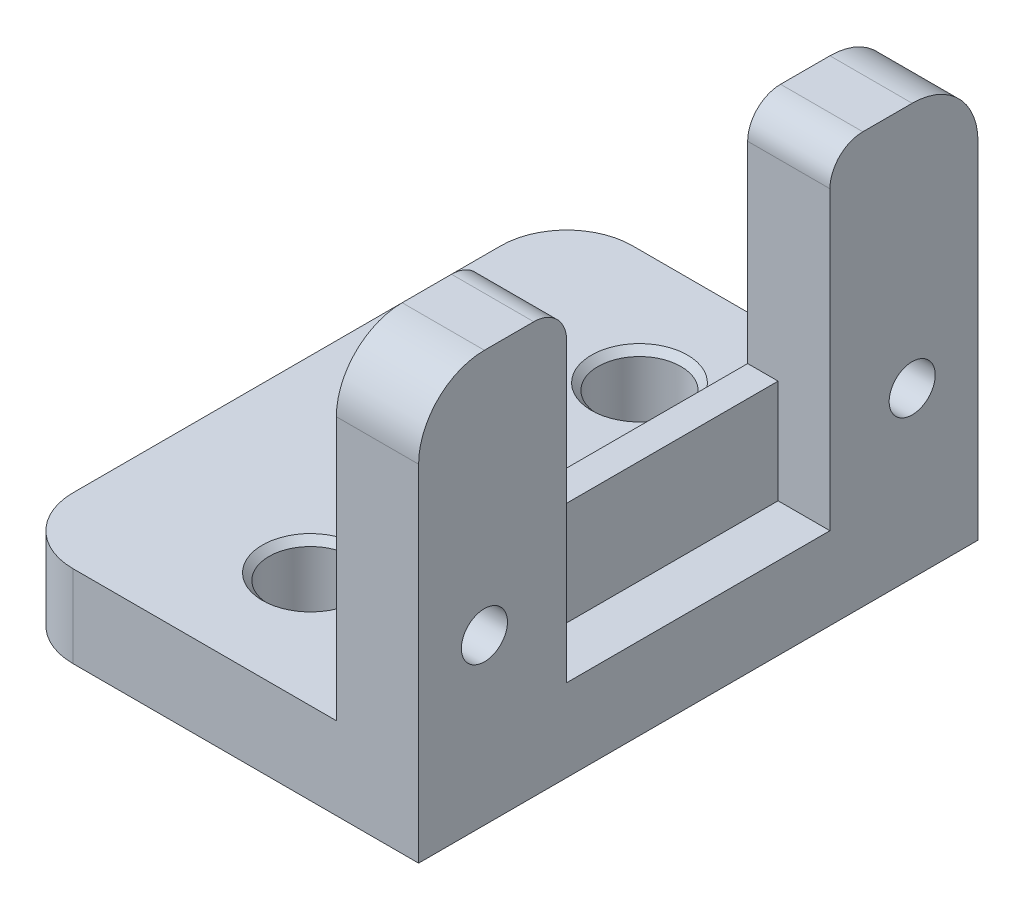
from build123d import *

# Parameters (mm, degrees)
BOSS_EXTRUDE1_DEPTH = 10.795
SKETCH2_R           = 0.889
SKETCH2_W           = 10.16
SKETCH2_H           = 12.7
CUT_EXTRUDE1_DEPTH  = 16.875
SKETCH3_R           = 1.6
CUT_EXTRUDE2_DEPTH  = 4.175
SKETCH5_W           = 1.175
SKETCH5_H           = 10.16
BOSS_EXTRUDE2_DEPTH = 4
CHAMFER1_SIZE       = 0.254
FILLET1_R           = 2.54
FILLET2_R           = 1.27


with BuildPart() as part:
    # Sketch1 → Boss-Extrude1 (new body, symmetric)
    with BuildSketch(Plane.XY):
        Polygon((-15.875, 0), (0, 0), (0, 15.875), (-3.175, 15.875), (-3.175, 3.175), (-15.875, 3.175), align=None)
    extrude(amount=BOSS_EXTRUDE1_DEPTH, both=True)

    # Sketch2 → Cut-Extrude1 (cut, through all)
    with BuildSketch(Plane(origin=(0, 0, 0), x_dir=(0, 0, -1), z_dir=(1, 0, 0))):
        with Locations((-8.255, 6.35)):
            Circle(SKETCH2_R)
        with Locations((8.255, 6.35)):
            Circle(SKETCH2_R)
        with Locations((0, 9.525)):
            Rectangle(SKETCH2_W, SKETCH2_H)
    extrude(amount=-CUT_EXTRUDE1_DEPTH, mode=Mode.SUBTRACT)

    # Sketch3 → Cut-Extrude2 (cut, through all)
    with BuildSketch(Plane(origin=(0, 3.175, 0), x_dir=(1, 0, 0), z_dir=(0, 1, 0))):
        with Locations((-8.62, 6.35)):
            Circle(SKETCH3_R)
        with Locations((-8.62, -6.35)):
            Circle(SKETCH3_R)
    extrude(amount=-CUT_EXTRUDE2_DEPTH, mode=Mode.SUBTRACT)

    # Sketch5 → Boss-Extrude2 (add)
    with BuildSketch(Plane(origin=(0, 3.175, 0), x_dir=(1, 0, 0), z_dir=(0, 1, 0))):
        with Locations((-2.5875, 0)):
            Rectangle(SKETCH5_W, SKETCH5_H)
    extrude(amount=BOSS_EXTRUDE2_DEPTH)

    # Chamfer1
    chamfer1_edges = [part.edges().sort_by_distance(p)[0] for p in [
        (-10.22, 3.175, -6.35),
        (-10.22, 3.175, 6.35),
    ]]
    chamfer(chamfer1_edges, length=CHAMFER1_SIZE)

    # Fillet1
    fillet1_edges = [part.edges().sort_by_distance(p)[0] for p in [
        (-1.5875, 15.875, 10.795),
        (-15.875, 1.5875, 10.795),
        (-1.5875, 15.875, -10.795),
        (-15.875, 1.5875, -10.795),
    ]]
    fillet(fillet1_edges, radius=FILLET1_R)

    # Fillet2
    fillet2_edges = [part.edges().sort_by_distance(p)[0] for p in [
        (-1.5875, 15.875, 5.08),
        (-1.5875, 15.875, -5.08),
    ]]
    fillet(fillet2_edges, radius=FILLET2_R)


solid = part.part
